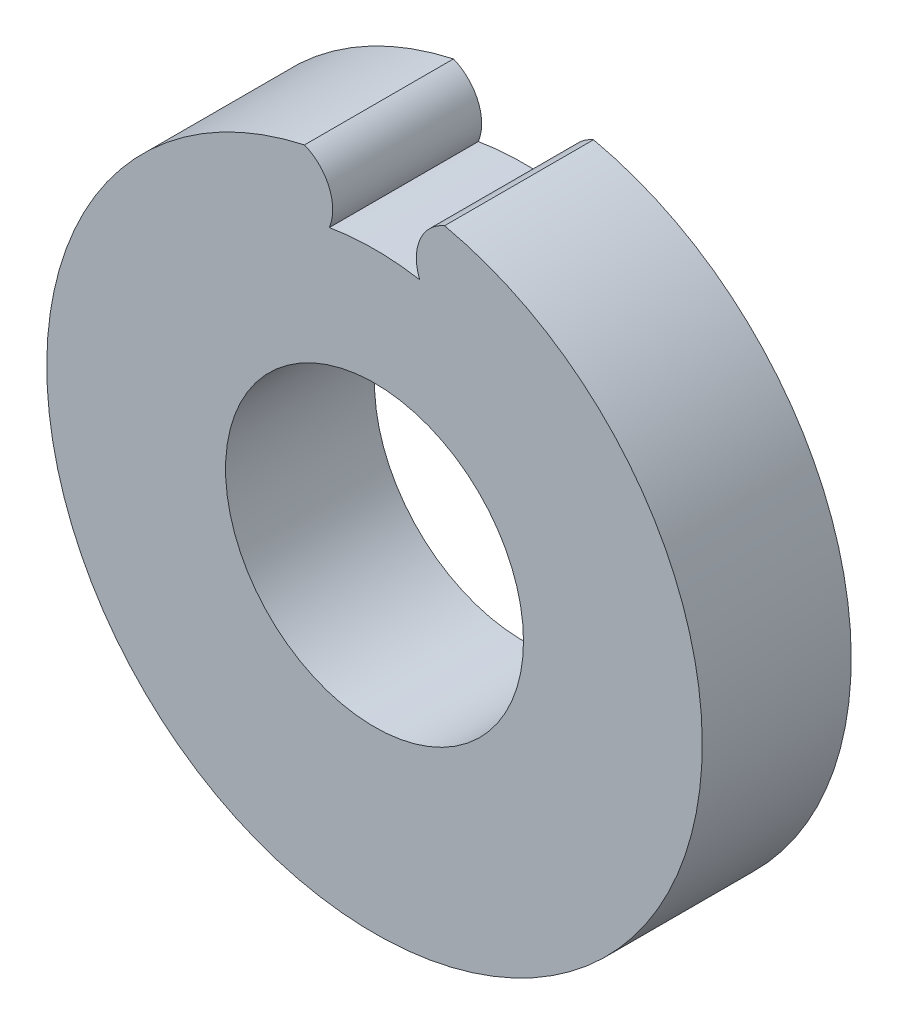
from build123d import *

# Parameters (mm, degrees)
SKETCH1_R           = 13.2
SKETCH1_R_2         = 6
BOSS_EXTRUDE1_DEPTH = 6
CUT_EXTRUDE1_DEPTH  = 7


with BuildPart() as part:
    # Sketch1 → Boss-Extrude1 (new body)
    with BuildSketch(Plane.XY):
        Circle(SKETCH1_R)
        Circle(SKETCH1_R_2, mode=Mode.SUBTRACT)
    extrude(amount=BOSS_EXTRUDE1_DEPTH)

    # Sketch2 → Cut-Extrude1 (cut, through all)
    with BuildSketch(Plane.XY.offset(6)):
        with BuildLine():
            ThreePointArc((-2.819851171, 12.895287487), (0, 13.2), (2.819851171, 12.895287487))
            ThreePointArc((2.819851171, 12.895287487), (1.826256171, 11.910750525), (1.819851171, 10.512))
            ThreePointArc((1.819851171, 10.512), (0, 10.668364555), (-1.819851171, 10.512))
            ThreePointArc((-1.819851171, 10.512), (-1.826256171, 11.910750525), (-2.819851171, 12.895287487))
        make_face()
    extrude(amount=-CUT_EXTRUDE1_DEPTH, mode=Mode.SUBTRACT)


solid = part.part
